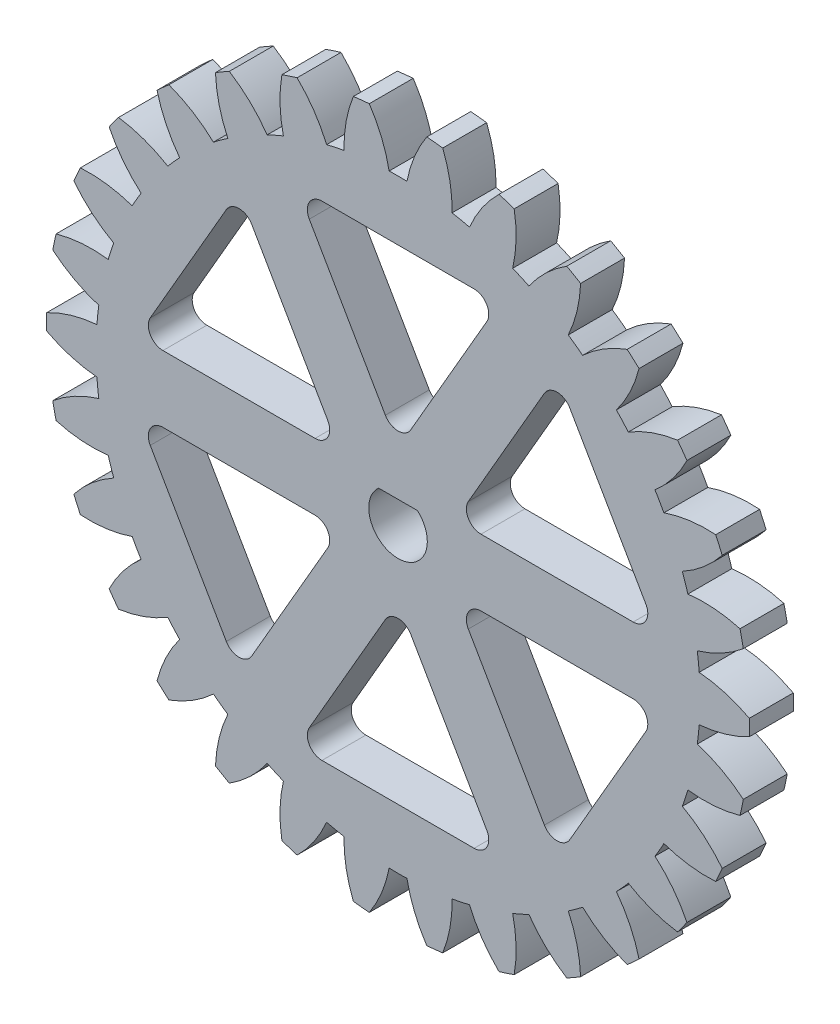
from build123d import *

# Parameters (mm, degrees)
SKETCH1_R                = 23.99999999999999
BOSS_EXTRUDE1_DEPTH      = 3
CUT_EXTRUDE1_DEPTH       = 35.07345007480163
CIRPATTERN1_COUNT        = 30
CUT_EXTRUDE3_DEPTH       = 35.01674497668011
FILLET1_R                = 1
CIRPATTERN4_COUNT        = 6
FILLET1_OF_CIRPATTERN4_R = 1
CUT_EXTRUDE4_DEPTH       = 10


with BuildPart() as part:
    # Sketch1 → Boss-Extrude1 (new body)
    with BuildSketch(Plane.XY):
        Circle(SKETCH1_R)
    extrude(amount=BOSS_EXTRUDE1_DEPTH)

    # Sketch7 → Cut-Extrude1 (cut, through all)
    with BuildSketch(Plane.XY.offset(3)):
        with BuildLine():
            ThreePointArc((-1.9649583180080463, 23.919425971550627), (-1.1209300481563567, 22.335720311039616), (-0.6078943285153203, 20.616039616894376))
            ThreePointArc((-0.6078943285153203, 20.616039616894376), (1.26e-15, 20.62499999999999), (0.6078943285153203, 20.616039616894376))
            ThreePointArc((0.6078943285153203, 20.616039616894376), (1.1209300481563567, 22.335720311039616), (1.9649583180080463, 23.919425971550627))
            ThreePointArc((1.9649583180080463, 23.919425971550627), (1.47e-15, 23.999999999999993), (-1.9649583180080463, 23.919425971550627))
        make_face()
    cut_extrude1 = extrude(amount=-CUT_EXTRUDE1_DEPTH, mode=Mode.SUBTRACT)

    # CirPattern1: Cut-Extrude1 ×30 about axis
    cirpattern1_axis = Axis((-3.01e-15, -1.4e-16, 0), (0, 0, 1))
    for i in range(1, CIRPATTERN1_COUNT):
        add(cut_extrude1.rotate(cirpattern1_axis, i * 360 / CIRPATTERN1_COUNT), mode=Mode.SUBTRACT)

    # Sketch8 → Cut-Extrude3 (cut, through all)
    with BuildSketch(Plane.XY.offset(3)):
        Polygon((7.6e-16, 4.542753790617738), (-6.928203230275515, 16.542753790617745), (6.928203230275508, 16.542753790617745), align=None)
    cut_extrude3 = extrude(amount=-CUT_EXTRUDE3_DEPTH, mode=Mode.SUBTRACT)

    # Fillet1
    fillet1_edges = [part.edges().sort_by_distance(p)[0] for p in [
        (7.6e-16, 4.542753790617738, 1.5),
        (-6.928203230275515, 16.542753790617745, 1.5),
        (6.928203230275508, 16.542753790617745, 1.5),
    ]]
    fillet(fillet1_edges, radius=FILLET1_R)

    # CirPattern4: Cut-Extrude3 ×6 about axis
    cirpattern4_axis = Axis((-1.031e-14, -4.9e-16, 0), (0, 0, 1))
    for i in range(1, CIRPATTERN4_COUNT):
        add(cut_extrude3.rotate(cirpattern4_axis, i * 360 / CIRPATTERN4_COUNT), mode=Mode.SUBTRACT)

    # Fillet1 of CirPattern4
    fillet1_of_cirpattern4_edges = [part.edges().sort_by_distance(p)[0] for p in [
        (-3.9341401858130207, 2.2713768953088787, 1.5),
        (-17.79054664636405, 2.2713768953088787, 1.5),
        (-10.862343416088535, 14.271376895308881, 1.5),
        (-3.9341401858130323, -2.2713768953088596, 1.5),
        (-10.862343416088548, -14.271376895308865, 1.5),
        (-17.790546646364053, -2.2713768953088618, 1.5),
        (-2.193e-14, -4.542753790617739, 1.5),
        (6.928203230275493, -16.542753790617745, 1.5),
        (-6.92820323027553, -16.542753790617745, 1.5),
        (3.934140185812999, -2.2713768953088813, 1.5),
        (17.790546646364028, -2.2713768953088858, 1.5),
        (10.86234341608851, -14.271376895308885, 1.5),
        (3.934140185813011, 2.2713768953088596, 1.5),
        (10.862343416088521, 14.27137689530887, 1.5),
        (17.790546646364035, 2.2713768953088667, 1.5),
    ]]
    fillet(fillet1_of_cirpattern4_edges, radius=FILLET1_OF_CIRPATTERN4_R)

    # Sketch9 → Cut-Extrude4 (cut)
    with BuildSketch(Plane(origin=(0, 0, 0), x_dir=(-1, 0, 0), z_dir=(0, 0, -1))):
        with BuildLine():
            Line((-1.3228756555322951, 1.5000000000000002), (1.3228756555322951, 1.5000000000000002))
            ThreePointArc((1.3228756555322951, 1.5000000000000002), (-3.7e-16, -2), (-1.3228756555322951, 1.5000000000000002))
        make_face()
    extrude(amount=-CUT_EXTRUDE4_DEPTH, mode=Mode.SUBTRACT)


solid = part.part
